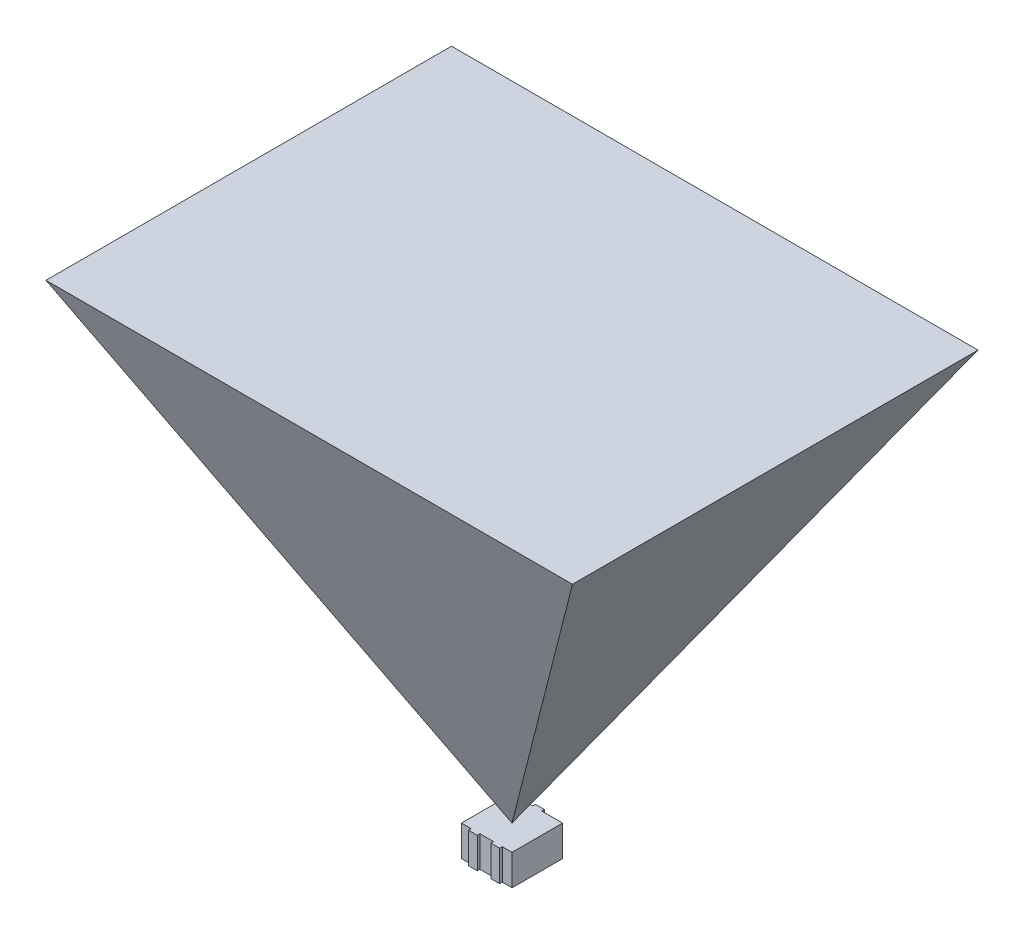
from build123d import *

# Parameters (mm, degrees)
AUFSATZ_LINEAR_AUSTRAGEN1_DEPTH      = 7
AUFSATZ_LINEAR_AUSTRAGEN2_DEPTH      = 100
AUFSATZ_LINEAR_AUSTRAGEN2_DEPTH_BACK = 100
SKIZZE3_OUTSIDE_W                    = 250.97
SKIZZE3_OUTSIDE_H                    = 157.97
SCHNITT_LINEAR_AUSTRAGEN1_DEPTH      = 100
SCHNITT_LINEAR_AUSTRAGEN1_DEPTH_BACK = 100


with BuildPart() as part:
    # Skizze1 → Aufsatz-Linear austragen1 (new body)
    with BuildSketch(Plane(origin=(0, 0, 0), x_dir=(1, 0, 0), z_dir=(0, 1, 0))):
        Polygon((-1, 5.75), (-1, 6.35), (1, 6.35), (1, 5.75), (5.75, 5.75), (5.75, -5.75), (3.55, -5.75), (3.55, -6.35), (1.55, -6.35), (1.55, -5.75), (0, -5.75), (-1.55, -5.75), (-1.55, -6.35), (-3.55, -6.35), (-3.55, -5.75), (-5.75, -5.75), (-5.75, 5.75), align=None)
    extrude(amount=AUFSATZ_LINEAR_AUSTRAGEN1_DEPTH)


with BuildPart() as body_2:
    # Skizze2 → Aufsatz-Linear austragen2 (new body, two sides)
    with BuildSketch(Plane(origin=(0, 0, 0), x_dir=(0, 0, -1), z_dir=(1, 0, 0))) as aufsatz_linear_austragen2_sk:
        Polygon((0, 7), (46.100631443, 107), (-46.100631443, 107), align=None)
    extrude(amount=AUFSATZ_LINEAR_AUSTRAGEN2_DEPTH)
    extrude(aufsatz_linear_austragen2_sk.sketch, amount=-AUFSATZ_LINEAR_AUSTRAGEN2_DEPTH_BACK)

    # Skizze3 outside → Schnitt-Linear austragen1 (cut, two sides)
    with BuildSketch(Plane.XY) as schnitt_linear_austragen1_sk:
        with Locations((0, 53.5)):
            Rectangle(SKIZZE3_OUTSIDE_W, SKIZZE3_OUTSIDE_H)
        Polygon((0, 7), (-59.848765359, 107), (59.848765359, 107), align=None, mode=Mode.SUBTRACT)
    extrude(amount=SCHNITT_LINEAR_AUSTRAGEN1_DEPTH, mode=Mode.SUBTRACT)
    extrude(schnitt_linear_austragen1_sk.sketch, amount=-SCHNITT_LINEAR_AUSTRAGEN1_DEPTH_BACK, mode=Mode.SUBTRACT)


solid = Compound([part.part, body_2.part])
